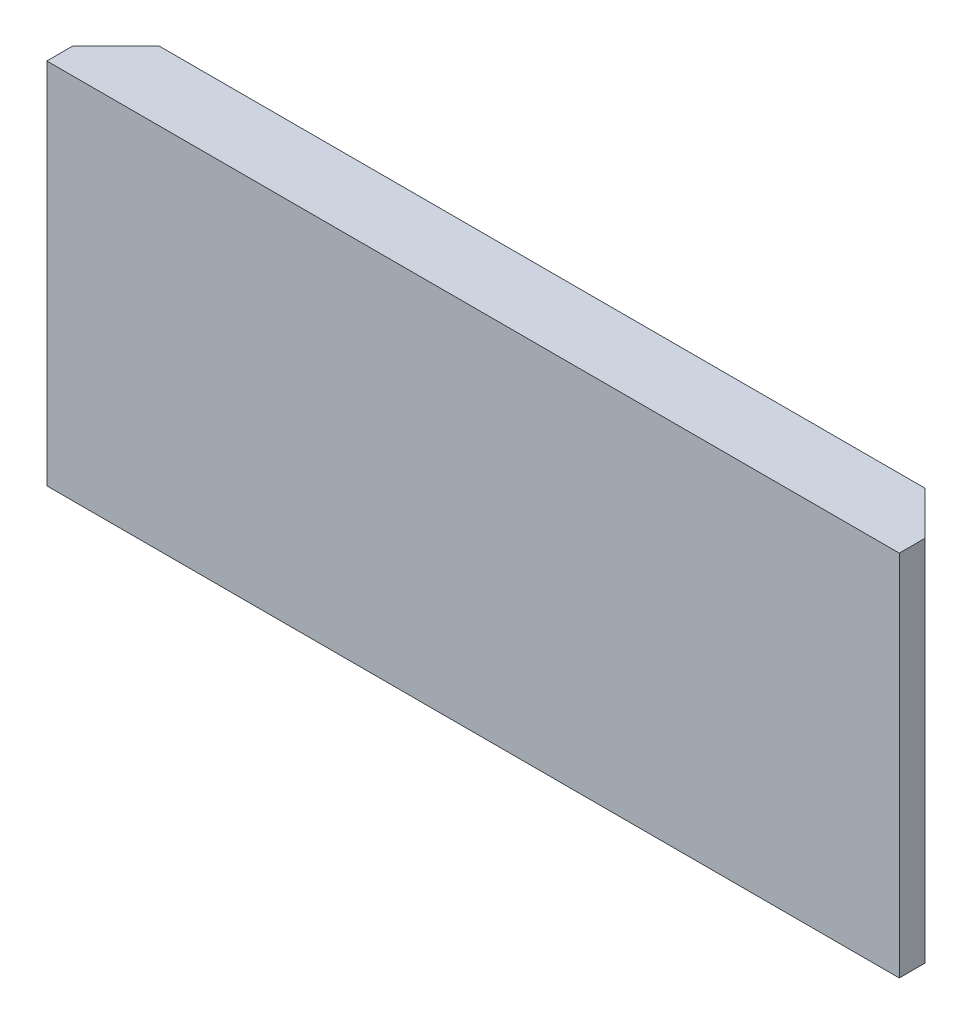
from build123d import *

# Parameters (mm, degrees)
SKETCH1_W           = 197.4
SKETCH1_H           = 85.209366976
BOSS_EXTRUDE1_DEPTH = 6
BOSS_EXTRUDE2_DEPTH = 10


with BuildPart() as part:
    # Sketch1 → Boss-Extrude1 (new body)
    with BuildSketch(Plane.XY):
        with Locations((20.35, 4.589716511)):
            Rectangle(SKETCH1_W, SKETCH1_H)
    extrude(amount=BOSS_EXTRUDE1_DEPTH)

    # Sketch2 → Boss-Extrude2 (add)
    with BuildSketch(Plane(origin=(0, 47.194399999, 0), x_dir=(1, 0, 0), z_dir=(0, 1, 0))):
        Polygon((-78.35, 0), (-68.35, 10), (109.05, 10), (119.05, 0), (119.05, -6), (-78.35, -6), align=None)
    extrude(amount=-BOSS_EXTRUDE2_DEPTH)


solid = part.part
